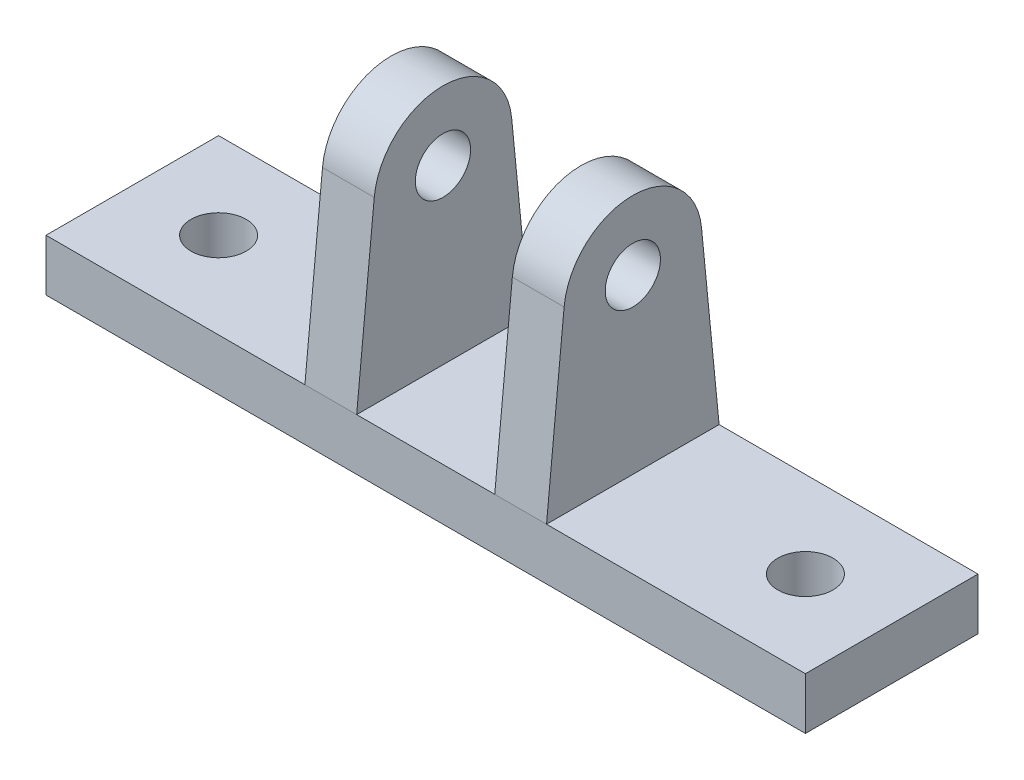
from build123d import *

# Parameters (mm, degrees)
SKETCH_1_W      = 44
SKETCH_1_H      = 10
SKETCH_1_R      = 1.6
EXTRUDE_1_DEPTH = 3
SKETCH_2_R      = 4
SKETCH_2_R_2    = 1.6
EXTRUDE_2_DEPTH = 3


with BuildPart() as part:
    # 草图1 → 凸台-拉伸1 (new body)
    with BuildSketch(Plane(origin=(0, 0, 0), x_dir=(1, 0, 0), z_dir=(0, 1, 0))):
        Rectangle(SKETCH_1_W, SKETCH_1_H)
        with Locations((17, 0)):
            Circle(SKETCH_1_R, mode=Mode.SUBTRACT)
        with Locations((-17, 0)):
            Circle(SKETCH_1_R, mode=Mode.SUBTRACT)
    extrude(amount=EXTRUDE_1_DEPTH)

    # 草图2 → 凸台-拉伸2 (add)
    with BuildSketch(Plane(origin=(4, 0, 0), x_dir=(0, 0, -1), z_dir=(1, 0, 0))):
        with BuildLine():
            Line((-5, 3), (5, 3))
            Line((5, 3), (3.980898083, 13.390449041))
            ThreePointArc((3.980898083, 13.390449041), (3.995221667, 13.195458012), (4, 13))
            ThreePointArc((4, 13), (-0.195458012, 9.004778333), (-3.980898083, 13.390449041))
            Line((-3.980898083, 13.390449041), (-5, 3))
        make_face()
        with Locations((0, 13)):
            Circle(SKETCH_2_R)
        with Locations((0, 13)):
            Circle(SKETCH_2_R_2, mode=Mode.SUBTRACT)
    extrude_2 = extrude(amount=EXTRUDE_2_DEPTH)

    # 镜向1: 凸台-拉伸2 across plane
    add(extrude_2.mirror(Plane(origin=(0, 0, 0), x_dir=(0, 0, 1), z_dir=(1, 0, 0))))


solid = part.part
